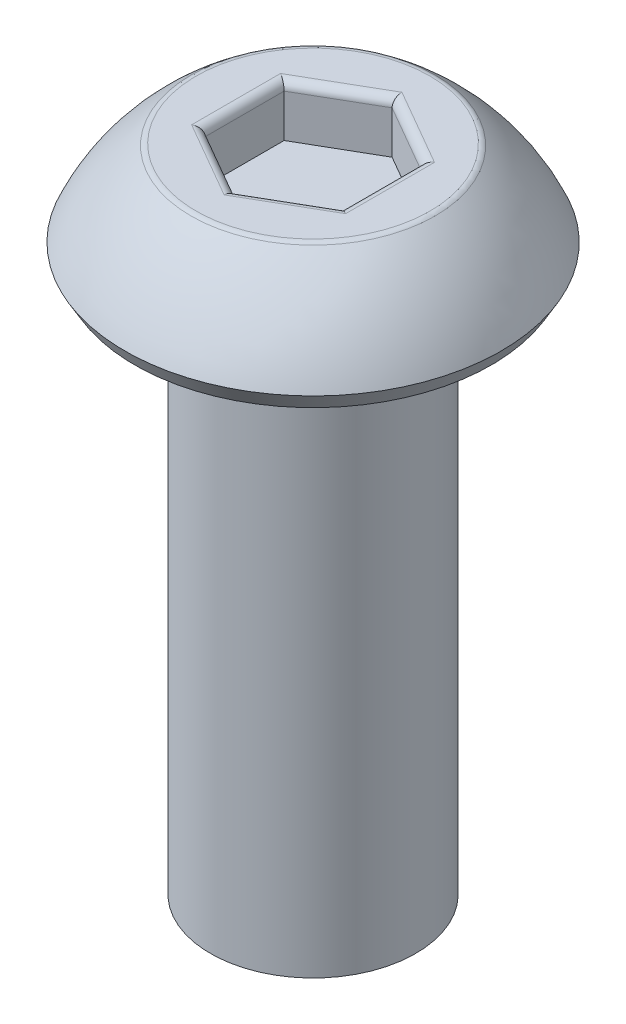
from build123d import *

# Parameters (mm, degrees)
CUT_EXTRUDE1_DEPTH = 0.75
FILLET1_R          = 0.125


with BuildPart() as part:
    # Sketch1 → Revolve1 (revolve)
    with BuildSketch(Plane(origin=(0, 0, 0), x_dir=(0, 0, -1), z_dir=(1, 0, 0))):
        with BuildLine():
            Line((0, 1.5), (-1.75, 1.5))
            ThreePointArc((-1.75, 1.5), (-2.334912942, 0.942930354), (-2.75, 0.25))
            Line((-2.75, 0.25), (-2.605662433, 0))
            Line((-2.605662433, 0), (-1.5, 0))
            Line((-1.5, 0), (-1.5, -8))
            Line((-1.5, -8), (0, -8))
            Line((0, -8), (0, 1.5))
        make_face()
    revolve(axis=Axis((0, -8, 0), (0, 1, 0)))

    # Sketch2 → Cut-Extrude1 (cut)
    with BuildSketch(Plane(origin=(0, 1.5, 0), x_dir=(1, 0, 0), z_dir=(0, 1, 0))):
        Polygon((0, 1.154700538), (-1, 0.577350269), (-1, -0.577350269), (0, -1.154700538), (1, -0.577350269), (1, 0.577350269), align=None)
    extrude(amount=-CUT_EXTRUDE1_DEPTH, mode=Mode.SUBTRACT)

    # Fillet1
    fillet1_edges = [part.edges().sort_by_distance(p)[0] for p in [
        (0.5, 1.5, -0.866025404),
        (-0.5, 1.5, -0.866025404),
        (-1, 1.5, 0),
        (-0.5, 1.5, 0.866025404),
        (0.5, 1.5, 0.866025404),
        (1, 1.5, 0),
        (0, 1.5, -1.75),
    ]]
    fillet(fillet1_edges, radius=FILLET1_R)


solid = part.part
